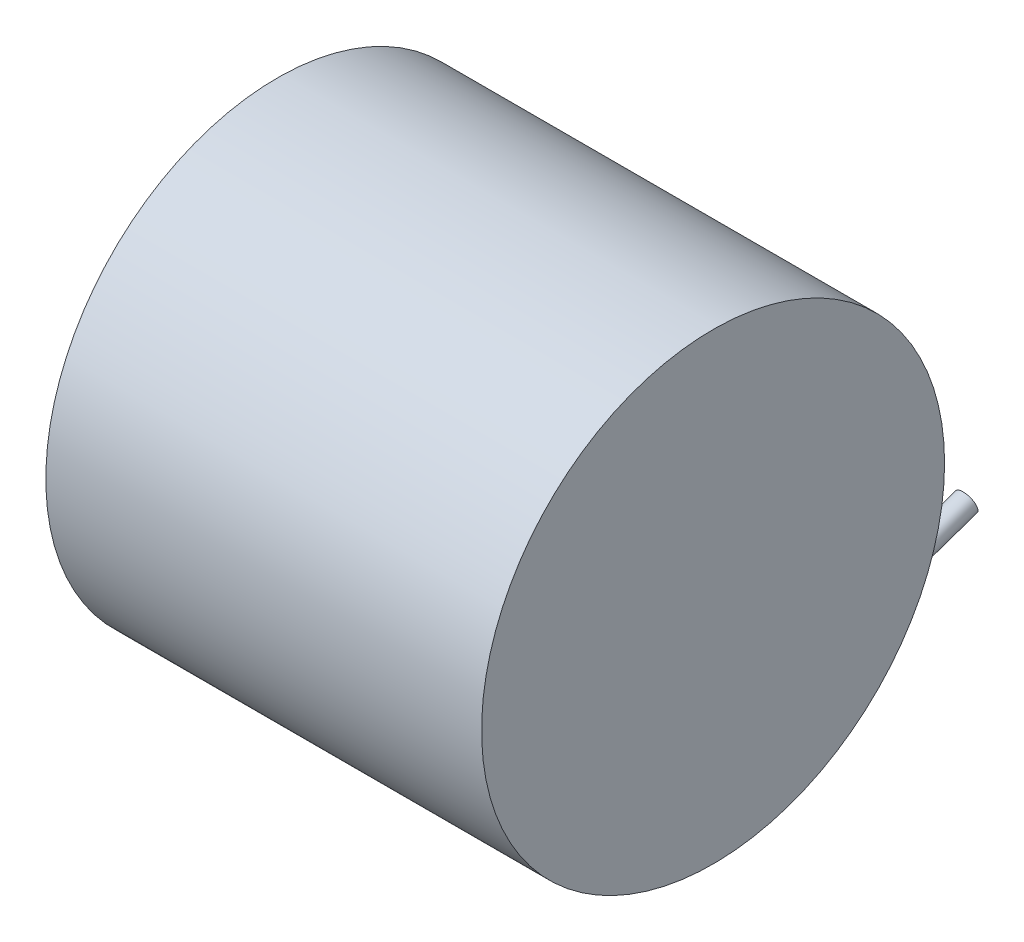
from build123d import *

# Parameters (mm, degrees)
SKETCH1_R           = 42.5
BOSS_EXTRUDE1_DEPTH = 40
SKETCH2_R           = 2
BOSS_EXTRUDE2_DEPTH = 15
SKETCH3_R           = 2
BOSS_EXTRUDE3_DEPTH = 30


with BuildPart() as part:
    # Sketch1 → Boss-Extrude1 (new body, symmetric)
    with BuildSketch(Plane(origin=(0, 0, 0), x_dir=(0, 0, -1), z_dir=(1, 0, 0))):
        Circle(SKETCH1_R)
    extrude(amount=BOSS_EXTRUDE1_DEPTH, both=True)

    # Sketch2 → Boss-Extrude2 (add)
    with BuildSketch(Plane.ZY.offset(40)):
        with Locations((-15.290703643, 5.288943408)):
            Circle(SKETCH2_R)
    extrude(amount=BOSS_EXTRUDE2_DEPTH)

    # Sketch3 → Boss-Extrude3 (add)
    with BuildSketch(Plane(origin=(0, 15.527284441, -44.890460433), x_dir=(-1, 0, 0), z_dir=(0, 0.326890199, -0.945062325))):
        with Locations((-30, -35.619517122)):
            Circle(SKETCH3_R)
    extrude(amount=-BOSS_EXTRUDE3_DEPTH)


solid = part.part
